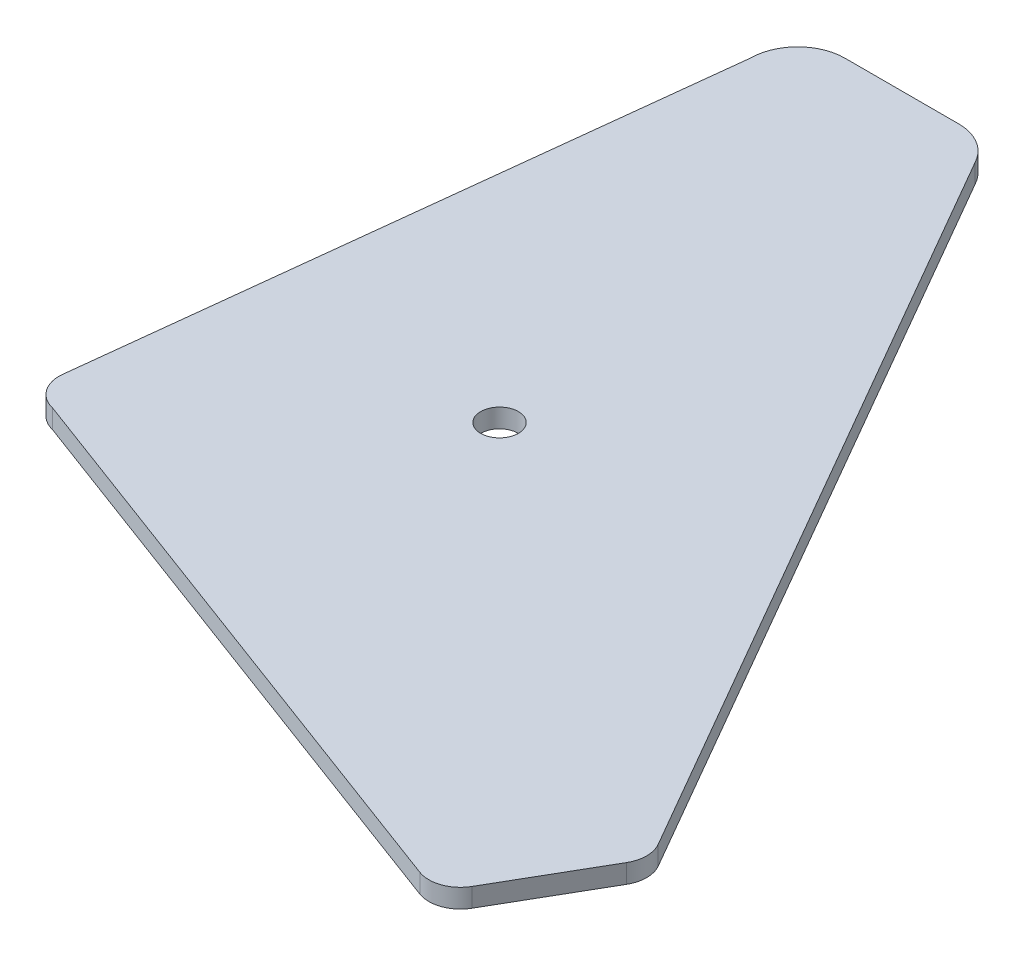
from build123d import *

# Parameters (mm, degrees)
SKETCH1_R           = 6
BOSS_EXTRUDE1_DEPTH = 6


with BuildPart() as part:
    # Sketch1 → Boss-Extrude1 (new body)
    with BuildSketch(Plane.XZ):
        with BuildLine():
            Line((633.54016476, -538), (596.941268489, -538.01196066))
            ThreePointArc((596.941268489, -538.01196066), (586.334666771, -533.618562378), (581.941268489, -523.01196066))
            Line((581.941268489, -523.01196066), (559.709119696, -326.819235636))
            ThreePointArc((559.709119696, -326.819235636), (561.462040963, -319.946040825), (567.332363616, -315.964476832))
            Line((567.332363616, -315.964476832), (753.41040417, -246.551436819))
            ThreePointArc((753.41040417, -246.551436819), (760.286617927, -246.509729538), (765.564086289, -250.917947183))
            Line((765.564086289, -250.917947183), (783.574274063, -282.088977586))
            ThreePointArc((783.574274063, -282.088977586), (784.915653972, -287.088539485), (783.577542101, -292.088977052))
            Line((783.577542101, -292.088977052), (646.316882655, -530.010943959))
            ThreePointArc((646.316882655, -530.010943959), (641.004531543, -535.726307145), (633.54016476, -538))
        make_face()
        with Locations((642.330973066, -382.939920306)):
            Circle(SKETCH1_R, mode=Mode.SUBTRACT)
    extrude(amount=BOSS_EXTRUDE1_DEPTH)


solid = part.part
